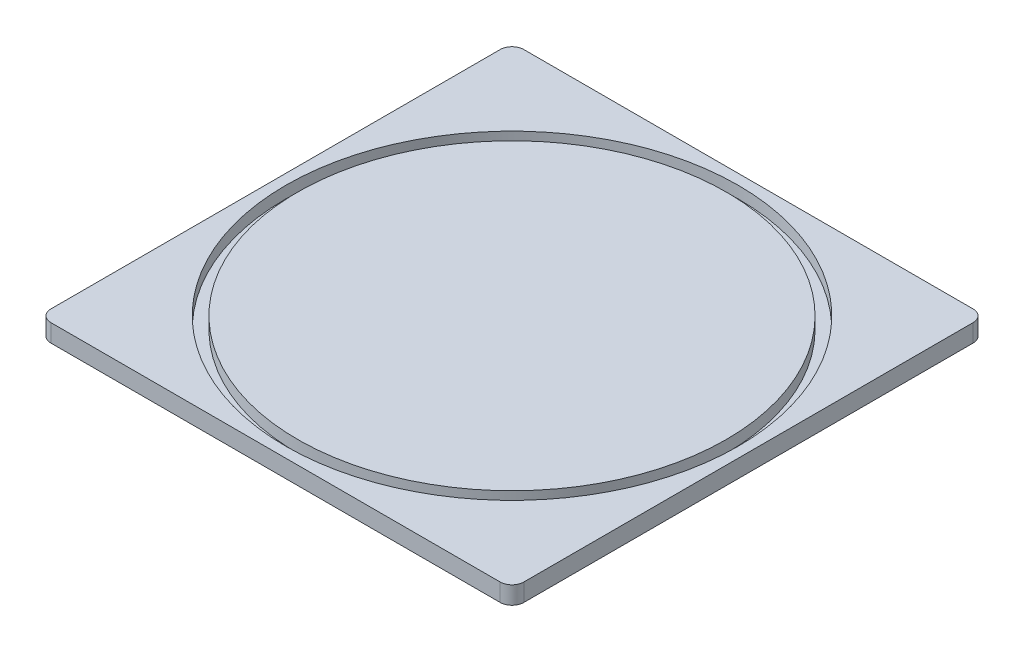
from build123d import *

# Parameters (mm, degrees)
SKETCH1_W               = 80
SKETCH1_H               = 80
BOSS_EXTRUDE1_DEPTH     = 3
SKETCH3_R               = 38.25
SKETCH3_R_2             = 36.25
CUT_EXTRUDE_THIN1_DEPTH = 2
FILLET1_R               = 2


with BuildPart() as part:
    # Sketch1 → Boss-Extrude1 (new body)
    with BuildSketch(Plane(origin=(0, 0, 0), x_dir=(1, 0, 0), z_dir=(0, 1, 0))):
        with Locations((40, 0)):
            Rectangle(SKETCH1_W, SKETCH1_H)
    extrude(amount=BOSS_EXTRUDE1_DEPTH)

    # Sketch3 → Cut-Extrude-Thin1 (cut)
    with BuildSketch(Plane(origin=(0, 3, 0), x_dir=(1, 0, 0), z_dir=(0, 1, 0))):
        with Locations((40, 0)):
            Circle(SKETCH3_R)
        with Locations((40, 0)):
            Circle(SKETCH3_R_2, mode=Mode.SUBTRACT)
    extrude(amount=-CUT_EXTRUDE_THIN1_DEPTH, mode=Mode.SUBTRACT)

    # Fillet1
    fillet1_edges = [part.edges().sort_by_distance(p)[0] for p in [
        (80, 1.5, -40),
        (80, 1.5, 40),
        (0, 1.5, 40),
        (0, 1.5, -40),
    ]]
    fillet(fillet1_edges, radius=FILLET1_R)


solid = part.part
